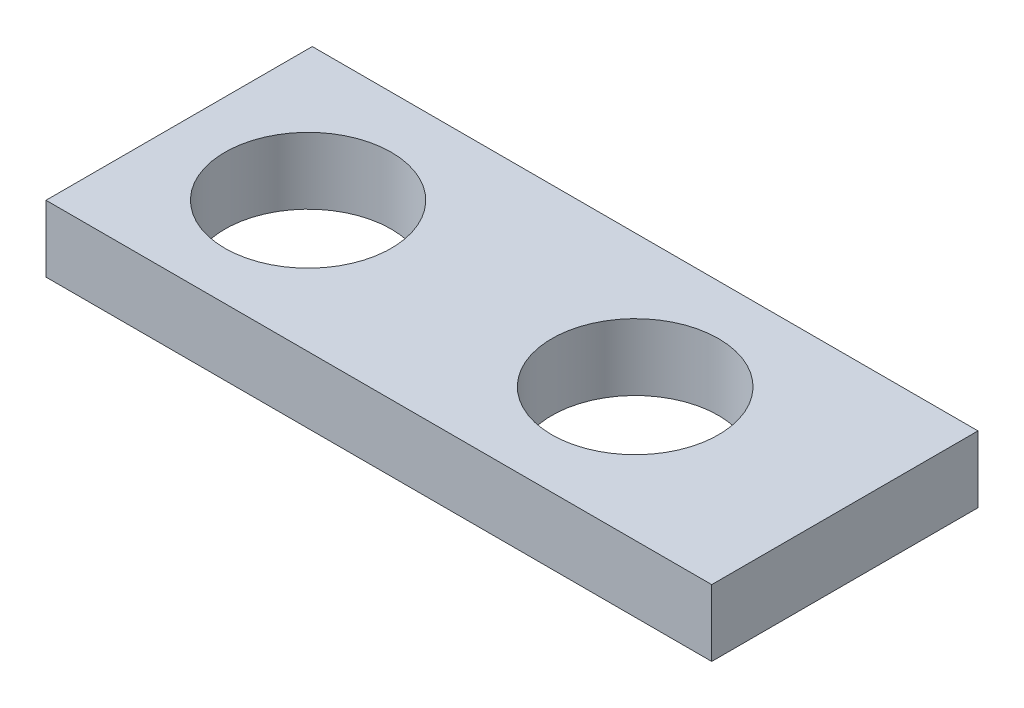
from build123d import *

# Parameters (mm, degrees)
SKETCH1_W           = 127
SKETCH1_H           = 50.8
BOSS_EXTRUDE1_DEPTH = 12.7
CUT_EXTRUDE1_DEPTH  = 12.7
CUT_EXTRUDE2_DEPTH  = 13.7


with BuildPart() as part:
    # Sketch1 → Boss-Extrude1 (new body)
    with BuildSketch(Plane(origin=(0, 0, 0), x_dir=(1, 0, 0), z_dir=(0, 1, 0))):
        with Locations((63.5, 25.4)):
            Rectangle(SKETCH1_W, SKETCH1_H)
    extrude(amount=BOSS_EXTRUDE1_DEPTH)

    # Sketch2 → Cut-Extrude1 (cut)
    with BuildSketch(Plane(origin=(0, 12.7, 0), x_dir=(1, 0, 0), z_dir=(0, 1, 0))):
        with BuildLine():
            ThreePointArc((9.125, 25), (13.774679849, 13.774679849), (25, 9.125))
            Line((25, 9.125), (25, 25))
            Line((25, 25), (9.125, 25))
        make_face()
        with BuildLine():
            Line((25, 25), (25, 9.125))
            ThreePointArc((25, 9.125), (36.225320151, 13.774679849), (40.875, 25))
            ThreePointArc((40.875, 25), (25, 40.875), (9.125, 25))
            Line((9.125, 25), (25, 25))
        make_face()
    extrude(amount=-CUT_EXTRUDE1_DEPTH, mode=Mode.SUBTRACT)

    # Sketch4 → Cut-Extrude2 (cut, through all)
    with BuildSketch(Plane(origin=(0, 12.7, 0), x_dir=(1, 0, 0), z_dir=(0, 1, 0))):
        with BuildLine():
            ThreePointArc((71.1, 25.4), (75.757002179, 14.157002179), (87, 9.5))
            Line((87, 9.5), (87, 25.4))
            Line((87, 25.4), (71.1, 25.4))
        make_face()
        with BuildLine():
            Line((87, 25.4), (87, 9.5))
            ThreePointArc((87, 9.5), (98.242997821, 14.157002179), (102.9, 25.4))
            ThreePointArc((102.9, 25.4), (87, 41.3), (71.1, 25.4))
            Line((71.1, 25.4), (87, 25.4))
        make_face()
    extrude(amount=-CUT_EXTRUDE2_DEPTH, mode=Mode.SUBTRACT)


solid = part.part
